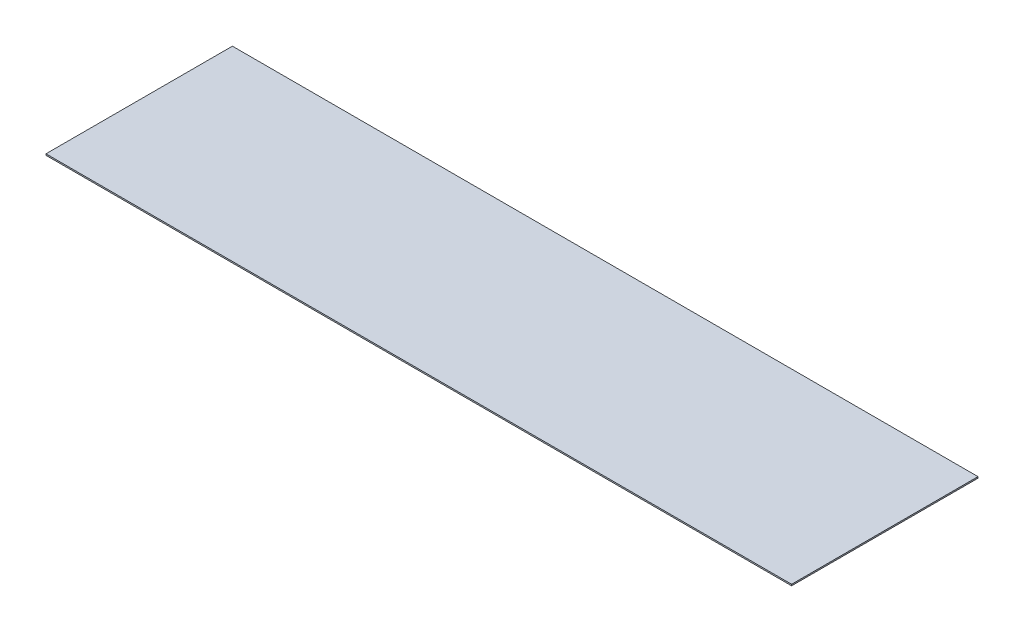
from build123d import *

# Parameters (mm, degrees)
SKETCH1_W           = 80
SKETCH1_H           = 20
BOSS_EXTRUDE1_DEPTH = 0.15


with BuildPart() as part:
    # Sketch1 → Boss-Extrude1 (new body)
    with BuildSketch(Plane(origin=(0, 0, 0), x_dir=(1, 0, 0), z_dir=(0, 1, 0))):
        Rectangle(SKETCH1_W, SKETCH1_H)
    extrude(amount=BOSS_EXTRUDE1_DEPTH)


solid = part.part
